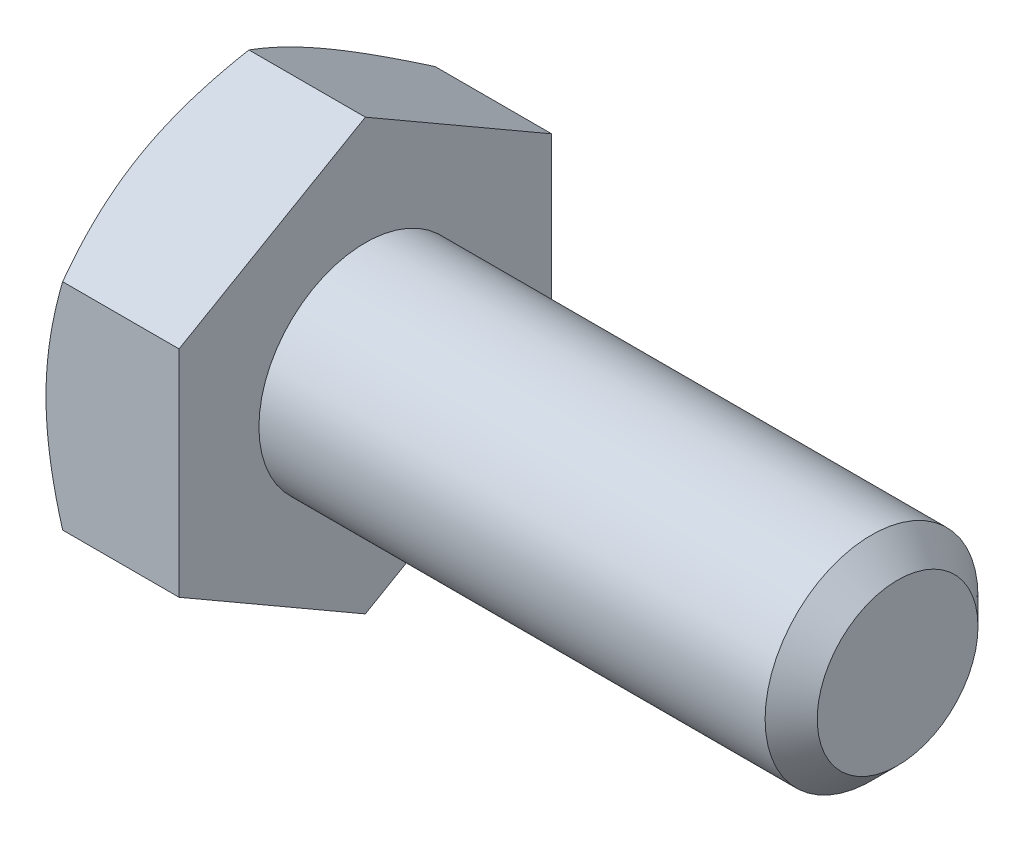
from build123d import *

# Parameters (mm, degrees)
SKETCH5_R           = 3.175
BOSS_EXTRUDE3_DEPTH = 15.875
CHAMFER1_SIZE       = 0.77724
BOSS_EXTRUDE4_DEPTH = 3.96875
SKETCH8_OUTSIDE_W   = 90.54
SKETCH8_OUTSIDE_H   = 92.26
SKETCH8_OUTSIDE_R   = 5.55625
CUT_EXTRUDE3_DEPTH  = 20.84375
CUT_EXTRUDE3_TAPER  = 60
CUT_EXTRUDE4_DEPTH  = 0.254
CIRPATTERN1_COUNT   = 3


with BuildPart() as part:
    # Sketch5 → Boss-Extrude3 (new body)
    with BuildSketch(Plane(origin=(9.921875, 0, 0), x_dir=(0, 0, -1), z_dir=(1, 0, 0))):
        Circle(SKETCH5_R)
    extrude(amount=-BOSS_EXTRUDE3_DEPTH)

    # Chamfer1
    chamfer1_edges = [part.edges().sort_by_distance(p)[0] for p in [
        (9.921875, 0, 3.175),
    ]]
    chamfer(chamfer1_edges, length=CHAMFER1_SIZE)

    # Sketch6 → Boss-Extrude4 (add)
    with BuildSketch(Plane.ZY.offset(5.953125)):
        Polygon((5.55625, 3.207902433), (0, 6.415804866), (-5.55625, 3.207902433), (-5.55625, -3.207902433), (0, -6.415804866), (5.55625, -3.207902433), align=None)
    extrude(amount=BOSS_EXTRUDE4_DEPTH)

    # Sketch8 outside → Cut-Extrude3 (cut, through all)
    with BuildSketch(Plane.ZY.offset(9.921875)):
        Rectangle(SKETCH8_OUTSIDE_W, SKETCH8_OUTSIDE_H)
        Circle(SKETCH8_OUTSIDE_R, mode=Mode.SUBTRACT)
    extrude(amount=-CUT_EXTRUDE3_DEPTH, taper=CUT_EXTRUDE3_TAPER, mode=Mode.SUBTRACT)

    # Sketch12 → Cut-Extrude4 (cut)
    with BuildSketch(Plane.ZY.offset(9.921875)):
        with BuildLine():
            Line((0.1666875, 4.2783125), (0.1666875, 2.3891875))
            ThreePointArc((0.1666875, 2.3891875), (0, 2.2225), (-0.1666875, 2.3891875))
            Line((-0.1666875, 2.3891875), (-0.1666875, 4.2783125))
            ThreePointArc((-0.1666875, 4.2783125), (0, 4.445), (0.1666875, 4.2783125))
        make_face()
    cut_extrude4 = extrude(amount=-CUT_EXTRUDE4_DEPTH, mode=Mode.SUBTRACT)

    # CirPattern1: Cut-Extrude4 ×3 about axis
    cirpattern1_axis = Axis((0, 0, 0), (1, 0, 0))
    for i in range(1, CIRPATTERN1_COUNT):
        add(cut_extrude4.rotate(cirpattern1_axis, i * 360 / CIRPATTERN1_COUNT), mode=Mode.SUBTRACT)


solid = part.part
